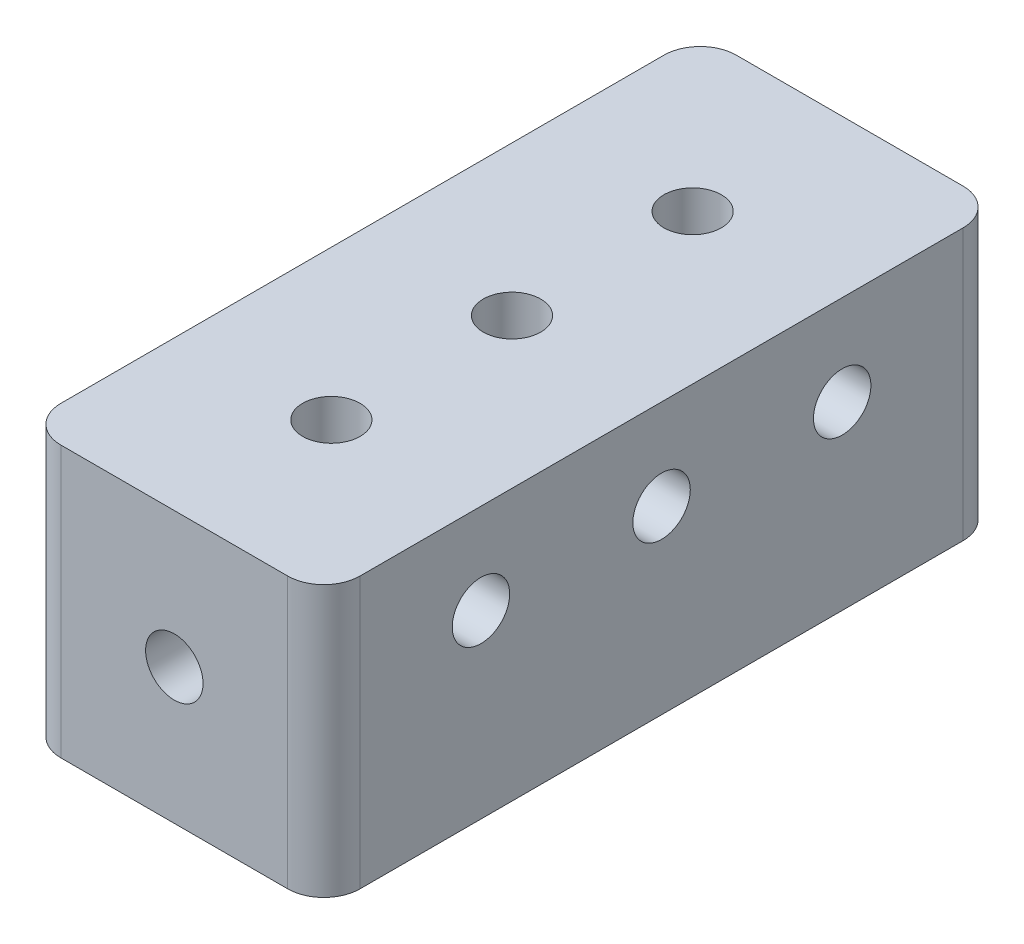
from build123d import *

# Parameters (mm, degrees)
SKETCH1_W           = 21.0312
SKETCH1_H           = 47.4853
BOSS_EXTRUDE1_DEPTH = 9.525
SKETCH2_R           = 2.0193
CUT_EXTRUDE1_DEPTH  = 9.525
SKETCH3_R           = 2.0193
CUT_EXTRUDE2_DEPTH  = 9.525
SKETCH4_R           = 2.0193
CUT_EXTRUDE3_DEPTH  = 6.35
SKETCH5_R           = 2.0193
CUT_EXTRUDE4_DEPTH  = 6.35
SKETCH6_R           = 2.0193
CUT_EXTRUDE5_DEPTH  = 6.35
FILLET1_R           = 2.54


with BuildPart() as part:
    # Sketch1 → Boss-Extrude1 (new body, symmetric)
    with BuildSketch(Plane(origin=(0, 0, 0), x_dir=(1, 0, 0), z_dir=(0, 1, 0))):
        Rectangle(SKETCH1_W, SKETCH1_H)
    extrude(amount=BOSS_EXTRUDE1_DEPTH, both=True)

    # Sketch2 → Cut-Extrude1 (cut)
    with BuildSketch(Plane.XY.offset(23.74265)):
        Circle(SKETCH2_R)
    extrude(amount=-CUT_EXTRUDE1_DEPTH, mode=Mode.SUBTRACT)

    # Sketch3 → Cut-Extrude2 (cut)
    with BuildSketch(Plane(origin=(0, 0, -23.74265), x_dir=(-1, 0, 0), z_dir=(0, 0, -1))):
        Circle(SKETCH3_R)
    extrude(amount=-CUT_EXTRUDE2_DEPTH, mode=Mode.SUBTRACT)

    # Sketch4 → Cut-Extrude3 (cut)
    with BuildSketch(Plane(origin=(10.5156, 0, 0), x_dir=(0, 0, -1), z_dir=(1, 0, 0))):
        with Locations((-12.7, 3.175)):
            Circle(SKETCH4_R)
        with Locations((12.7, 3.175)):
            Circle(SKETCH4_R)
        with Locations((0, 3.175)):
            Circle(SKETCH4_R)
    extrude(amount=-CUT_EXTRUDE3_DEPTH, mode=Mode.SUBTRACT)

    # Sketch5 → Cut-Extrude4 (cut)
    with BuildSketch(Plane.ZY.offset(10.5156)):
        with Locations((-12.7, 3.175)):
            Circle(SKETCH5_R)
        with Locations((0, 3.175)):
            Circle(SKETCH5_R)
        with Locations((12.7, 3.175)):
            Circle(SKETCH5_R)
    extrude(amount=-CUT_EXTRUDE4_DEPTH, mode=Mode.SUBTRACT)

    # Sketch6 → Cut-Extrude5 (cut)
    with BuildSketch(Plane(origin=(0, 9.525, 0), x_dir=(1, 0, 0), z_dir=(0, 1, 0))):
        with Locations((0, 12.7)):
            Circle(SKETCH6_R)
        Circle(SKETCH6_R)
        with Locations((0, -12.7)):
            Circle(SKETCH6_R)
    extrude(amount=-CUT_EXTRUDE5_DEPTH, mode=Mode.SUBTRACT)

    # Fillet1
    fillet1_edges = [part.edges().sort_by_distance(p)[0] for p in [
        (10.5156, 0, 23.74265),
        (-10.5156, 0, 23.74265),
        (-10.5156, 0, -23.74265),
        (10.5156, 0, -23.74265),
    ]]
    fillet(fillet1_edges, radius=FILLET1_R)


solid = part.part
